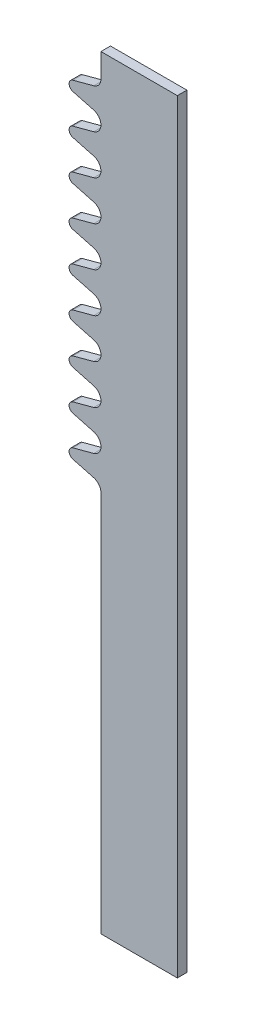
from build123d import *

# Parameters (mm, degrees)
SKETCH1_W           = 3.4
SKETCH1_H           = 24
BOSS_EXTRUDE1_DEPTH = 0.3
CUT_EXTRUDE1_DEPTH  = 1.3
CUT_EXTRUDE2_DEPTH  = 1.3
LPATTERN1_COUNT     = 9
LPATTERN1_PITCH     = 1.25
CUT_EXTRUDE4_DEPTH  = 1.3


with BuildPart() as part:
    # Sketch1 → Boss-Extrude1 (new body)
    with BuildSketch(Plane.XY):
        Rectangle(SKETCH1_W, SKETCH1_H)
    extrude(amount=-BOSS_EXTRUDE1_DEPTH)

    # Sketch2 → Cut-Extrude1 (cut, through all)
    with BuildSketch(Plane.XY):
        with BuildLine():
            Line((-1.7, -12), (-0.7, -12))
            Line((-0.7, -12), (-0.7, 0))
            ThreePointArc((-0.7, 0), (-0.763092877, 0.185865622), (-0.926295644, 0.294914224))
            Line((-0.926295644, 0.294914224), (-1.581411047, 0.470451868))
            ThreePointArc((-1.581411047, 0.470451868), (-1.666936534, 0.527598171), (-1.7, 0.625))
            Line((-1.7, 0.625), (-1.7, -12))
        make_face()
    extrude(amount=-CUT_EXTRUDE1_DEPTH, mode=Mode.SUBTRACT)

    # Sketch3 → Cut-Extrude2 (cut, through all)
    with BuildSketch(Plane.XY):
        with BuildLine():
            Line((-1.581411047, 0.779548132), (-0.926295644, 0.955085776))
            ThreePointArc((-0.926295644, 0.955085776), (-0.7, 1.25), (-0.926295644, 1.544914224))
            Line((-0.926295644, 1.544914224), (-1.581411047, 1.720451868))
            ThreePointArc((-1.581411047, 1.720451868), (-1.666936534, 1.777598171), (-1.7, 1.875))
            Line((-1.7, 1.875), (-1.7, 0.625))
            ThreePointArc((-1.7, 0.625), (-1.666936534, 0.722401829), (-1.581411047, 0.779548132))
        make_face()
    cut_extrude2 = extrude(amount=-CUT_EXTRUDE2_DEPTH, mode=Mode.SUBTRACT)

    # LPattern1: Cut-Extrude2 ×9
    with Locations(*[(0, i * LPATTERN1_PITCH, 0) for i in range(1, LPATTERN1_COUNT)]):
        add(cut_extrude2, mode=Mode.SUBTRACT)

    # Sketch4 → Cut-Extrude4 (cut, through all)
    with BuildSketch(Plane.XY):
        with BuildLine():
            Line((-0.7, 11.25), (-0.7, 12))
            Line((-0.7, 12), (-1.7, 12))
            Line((-1.7, 12), (-1.7, 11.875))
            ThreePointArc((-1.7, 11.875), (-1.666936534, 11.777598171), (-1.581411047, 11.720451868))
            Line((-1.581411047, 11.720451868), (-0.926295644, 11.544914224))
            ThreePointArc((-0.926295644, 11.544914224), (-0.763092877, 11.435865622), (-0.7, 11.25))
        make_face()
    extrude(amount=-CUT_EXTRUDE4_DEPTH, mode=Mode.SUBTRACT)


solid = part.part
